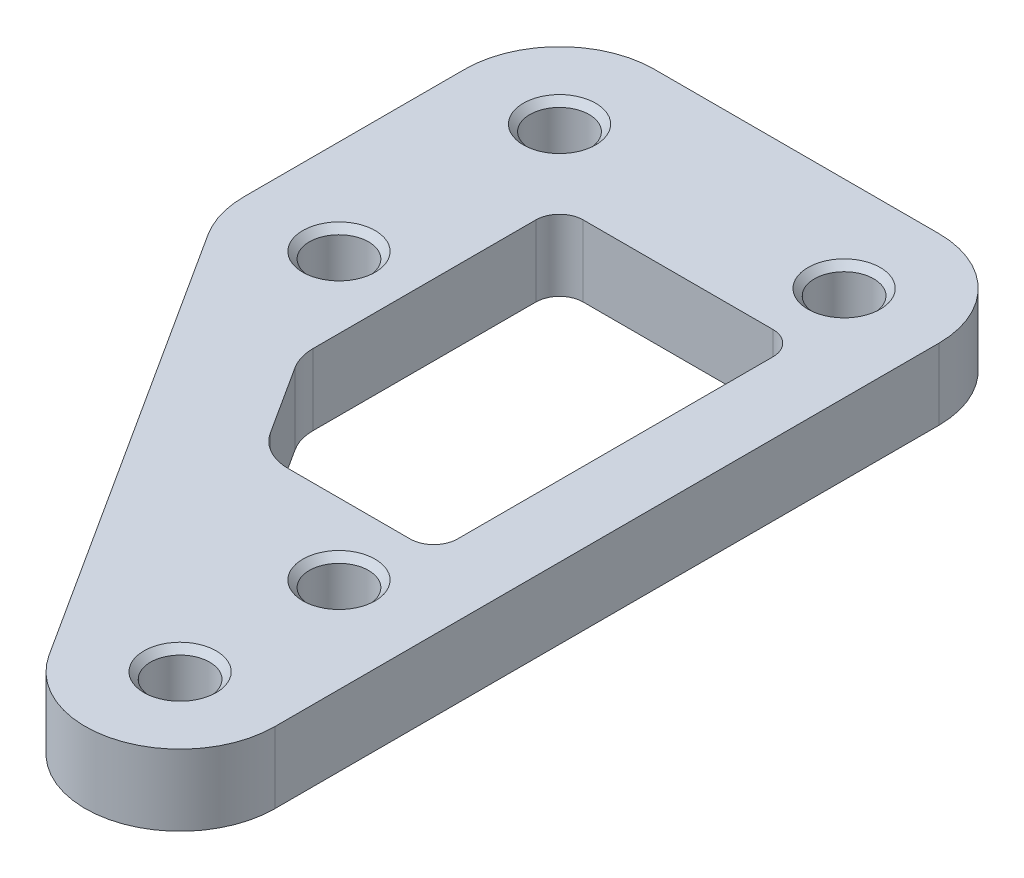
from build123d import *

# Parameters (mm, degrees)
EXTRUDE_1_DEPTH              = 3
HOLE_WIZARD_M3_1_D           = 2.5
HOLE_WIZARD_M3_1_CSINK_D     = 3.05
HOLE_WIZARD_M3_1_CSINK_ANGLE = 90


with BuildPart() as part:
    # 草图1 → 凸台-拉伸1 (new body)
    with BuildSketch(Plane(origin=(0, 0, 0), x_dir=(1, 0, 0), z_dir=(0, 1, 0))):
        with BuildLine():
            Line((4, -28), (4, 0))
            ThreePointArc((4, 0), (2.828427125, 2.828427125), (0, 4))
            Line((0, 4), (-12, 4))
            ThreePointArc((-12, 4), (-14.828427125, 2.828427125), (-16, 0))
            Line((-16, 0), (-16, -9.3))
            ThreePointArc((-16, -9.3), (-15.83835057, -10.425639773), (-15.366467551, -11.460300033))
            Line((-15.366467551, -11.460300033), (-3.366467551, -30.160300033))
            ThreePointArc((-3.366467551, -30.160300033), (1.125639773, -31.83835057), (4, -28))
        make_face()
        with BuildLine():
            Line((-8.683233775, -14.468627367), (-6.814876995, -17.380150016))
            ThreePointArc((-6.814876995, -17.380150016), (-6.09073132, -18.055035617), (-5.13164322, -18.3))
            Line((-5.13164322, -18.3), (0, -18.3))
            ThreePointArc((0, -18.3), (0.707106781, -18.007106781), (1, -17.3))
            Line((1, -17.3), (1, -4))
            ThreePointArc((1, -4), (0.707106781, -3.292893219), (0, -3))
            Line((0, -3), (-8, -3))
            ThreePointArc((-8, -3), (-8.707106781, -3.292893219), (-9, -4))
            Line((-9, -4), (-9, -13.388477351))
            ThreePointArc((-9, -13.388477351), (-8.919175285, -13.951297237), (-8.683233775, -14.468627367))
        make_face(mode=Mode.SUBTRACT)
    extrude(amount=EXTRUDE_1_DEPTH)

    # M3 螺纹孔1 (through all)
    with Locations(Plane(origin=(0, 3, 0), x_dir=(1, 0, 0), z_dir=(0, 1, 0))):
        with Locations((-12, 0), (-12, -9.3), (0, 0), (0, -21.3), (0, -28)):
            CounterSinkHole(HOLE_WIZARD_M3_1_D / 2, HOLE_WIZARD_M3_1_CSINK_D / 2, counter_sink_angle=HOLE_WIZARD_M3_1_CSINK_ANGLE)


solid = part.part
